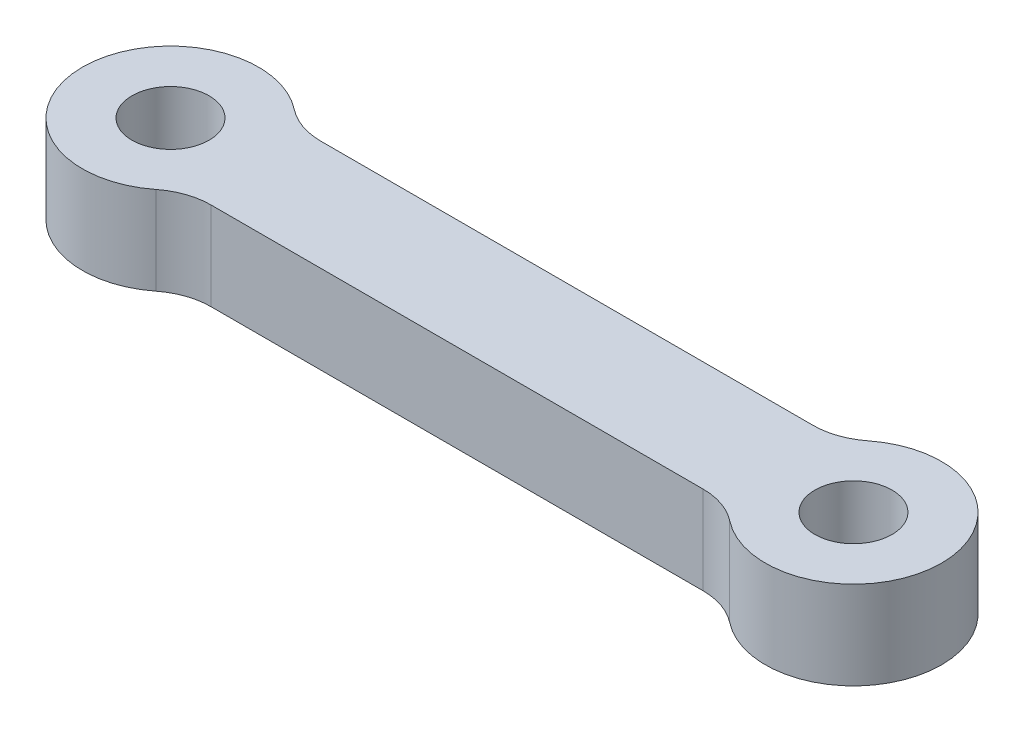
from build123d import *

# Parameters (mm, degrees)
SKETCH1_R           = 1750
BOSS_EXTRUDE1_DEPTH = 4000
FILLET1_R           = 3000


with BuildPart() as part:
    # Sketch1 → Boss-Extrude1 (new body)
    with BuildSketch(Plane(origin=(0, 0, 0), x_dir=(1, 0, 0), z_dir=(0, 1, 0))):
        with BuildLine():
            Line((27877.501000801, 2500), (3122.498999199, 2500))
            ThreePointArc((3122.498999199, 2500), (-4000, 0), (3122.498999199, -2500))
            Line((3122.498999199, -2500), (27877.501000801, -2500))
            ThreePointArc((27877.501000801, -2500), (35000, 0), (27877.501000801, 2500))
        make_face()
        Circle(SKETCH1_R, mode=Mode.SUBTRACT)
        with Locations((31000, 0)):
            Circle(SKETCH1_R, mode=Mode.SUBTRACT)
    extrude(amount=BOSS_EXTRUDE1_DEPTH)

    # Fillet1
    fillet1_edges = [part.edges().sort_by_distance(p)[0] for p in [
        (27877.501000801, 2000, 2500),
        (3122.498999199, 2000, 2500),
        (3122.498999199, 2000, -2500),
        (27877.501000801, 2000, -2500),
    ]]
    fillet(fillet1_edges, radius=FILLET1_R)


solid = part.part
